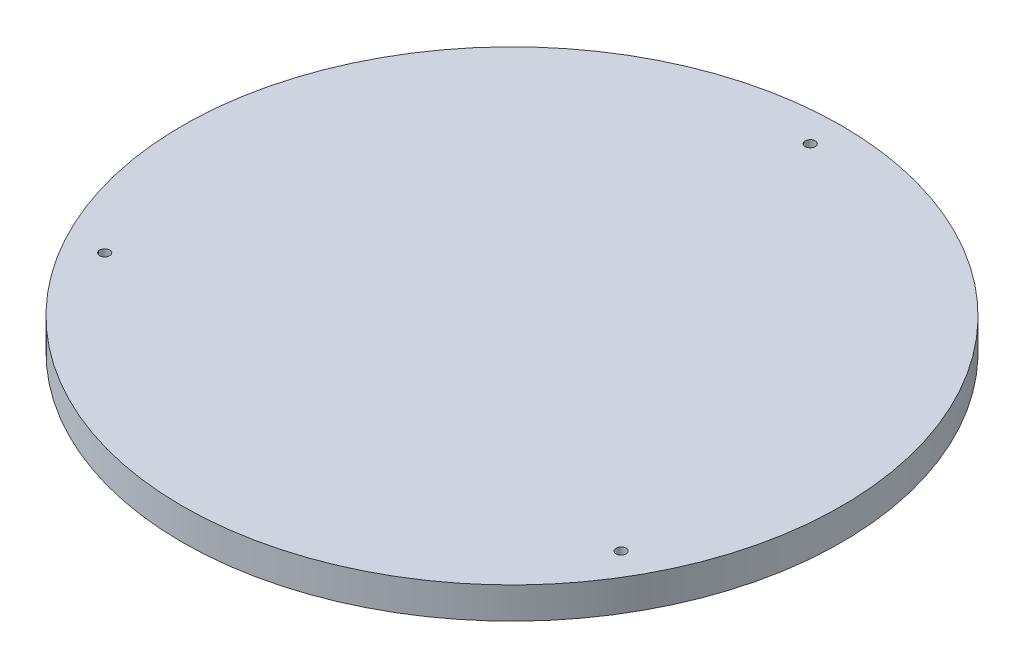
from build123d import *

# Parameters (mm, degrees)
SKETCH1_R           = 105
BOSS_EXTRUDE1_DEPTH = 10
SKETCH3_R           = 1.6
CUT_EXTRUDE1_DEPTH  = 47


with BuildPart() as part:
    # Sketch1 → Boss-Extrude1 (new body)
    with BuildSketch(Plane(origin=(0, 0, 0), x_dir=(1, 0, 0), z_dir=(0, 1, 0))):
        Circle(SKETCH1_R)
    extrude(amount=BOSS_EXTRUDE1_DEPTH)

    # Sketch3 → Cut-Extrude1 (cut)
    with BuildSketch(Plane(origin=(0, 10, 0), x_dir=(1, 0, 0), z_dir=(0, 1, 0))):
        with Locations((-82.27241336, -47.5)):
            Circle(SKETCH3_R)
        with Locations((0, 95)):
            Circle(SKETCH3_R)
        with Locations((82.27241336, -47.5)):
            Circle(SKETCH3_R)
    extrude(amount=-CUT_EXTRUDE1_DEPTH, mode=Mode.SUBTRACT)


solid = part.part
